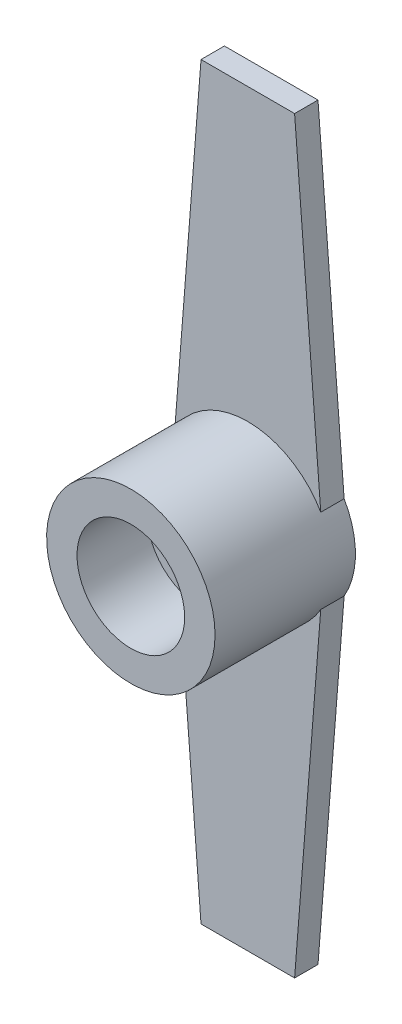
from build123d import *

# Parameters (mm, degrees)
SALIENTE_EXTRUIR1_DEPTH = 1
CROQUIS2_R              = 3.6
SALIENTE_EXTRUIR2_DEPTH = 5
CROQUIS3_R              = 2.3
CORTAR_EXTRUIR1_DEPTH   = 3


with BuildPart() as part:
    # Croquis1 → Saliente-Extruir1 (new body)
    with BuildSketch(Plane.XY):
        with BuildLine():
            Line((-2, -16), (2, -16))
            Line((2, -16), (3.117691454, -1.8))
            ThreePointArc((3.117691454, -1.8), (3.6, 0), (3.117691454, 1.8))
            Line((3.117691454, 1.8), (2, 16))
            Line((2, 16), (-2, 16))
            Line((-2, 16), (-3.117691454, 1.8))
            ThreePointArc((-3.117691454, 1.8), (-3.6, 0), (-3.117691454, -1.8))
            Line((-3.117691454, -1.8), (-2, -16))
        make_face()
    extrude(amount=SALIENTE_EXTRUIR1_DEPTH)

    # Croquis2 → Saliente-Extruir2 (add)
    with BuildSketch(Plane.XY.offset(1)):
        Circle(CROQUIS2_R)
    extrude(amount=SALIENTE_EXTRUIR2_DEPTH)

    # Croquis3 → Cortar-Extruir1 (cut)
    with BuildSketch(Plane.XY.offset(6)):
        Circle(CROQUIS3_R)
    extrude(amount=-CORTAR_EXTRUIR1_DEPTH, mode=Mode.SUBTRACT)


solid = part.part
